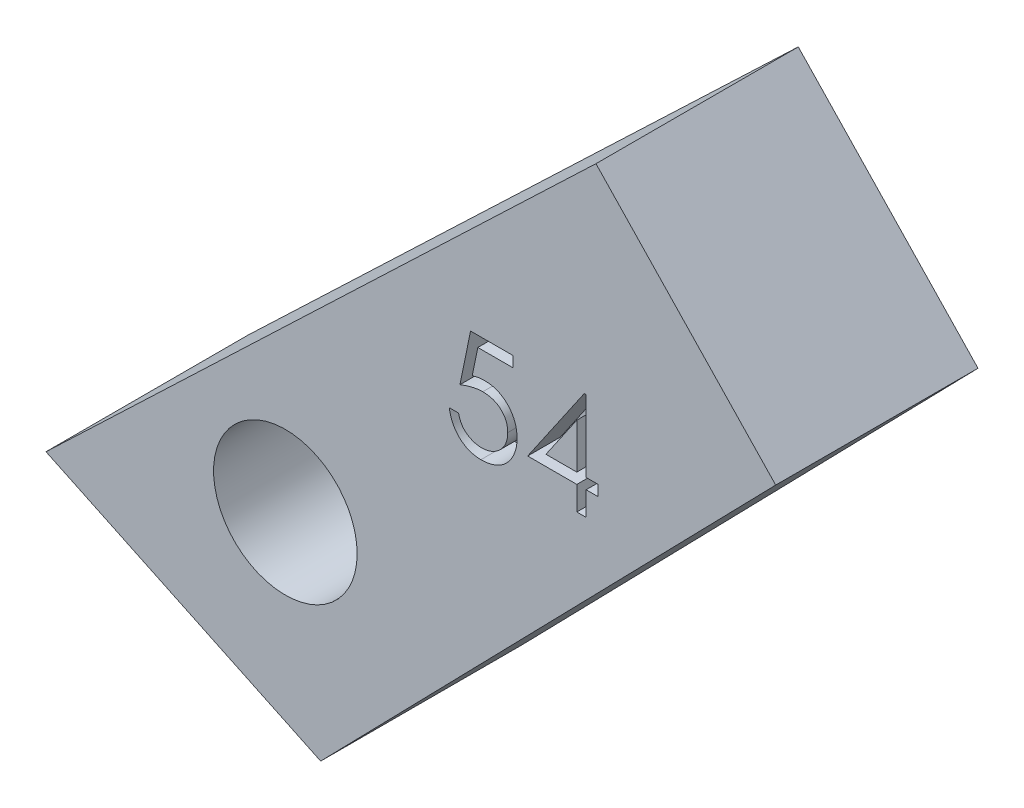
from build123d import *

# Parameters (mm, degrees)
SKETCH1_R           = 2.2
BOSS_EXTRUDE1_DEPTH = 6.2
CUT_EXTRUDE1_DEPTH  = 1


with BuildPart() as part:
    # Sketch1 → Boss-Extrude1 (new body)
    with BuildSketch(Plane(origin=(0, 0, 0), x_dir=(-1, 0, 0), z_dir=(0, 0, 1))):
        Polygon((-135.861235396, 102.40882942), (-149.806405315, 88.109421961), (-144.298520867, 82.333425686), (-134.435779681, 91.738355366), (-127.443880814, 98.405702296), align=None)
        with Locations((-134.779596853, 96.344682986)):
            Circle(SKETCH1_R, mode=Mode.SUBTRACT)
    extrude(amount=BOSS_EXTRUDE1_DEPTH)

    # Sketch2 → Cut-Extrude1 (cut)
    with BuildSketch(Plane.XY.offset(6.2)):
        with BuildLine():
            Line((141.757865871, -88.696242194), (141.757865871, -89.021883219))
            Line((141.757865871, -89.021883219), (140.677907938, -89.021883219))
            Line((140.677907938, -89.021883219), (140.506819196, -89.856974365))
            add(Edge.make_bspline(
                [(140.506819196, -89.856974365), (140.540434168, -89.847694047), (140.605557859, -89.829714899), (140.70167859, -89.809752521), (140.792930089, -89.797718869), (140.852144175, -89.796075751), (140.880797562, -89.795280655)],
                knots=[0, 0, 0, 0, 0.000104595, 0.000202637, 0.000294305, 0.000380252, 0.000380252, 0.000380252, 0.000380252], degree=3))
            add(Edge.make_bspline(
                [(140.880797562, -89.795280655), (140.916252097, -89.79604804), (140.985964572, -89.79755691), (141.087962759, -89.812045659), (141.185329027, -89.834851153), (141.277859748, -89.866710483), (141.365726105, -89.907450027), (141.448119678, -89.958340687), (141.526277214, -90.01778878), (141.598796567, -90.08613747), (141.664586475, -90.161359222), (141.722431337, -90.242238148), (141.771564544, -90.327988241), (141.811080372, -90.419428794), (141.842634732, -90.515548883), (141.863636899, -90.617359868), (141.877622056, -90.723902092), (141.879184507, -90.796749809), (141.879981255, -90.833897442)],
                knots=[0, 0, 0, 0, 0.000106308, 0.000209029, 0.000308378, 0.000405929, 0.000502102, 0.000598312, 0.00069588, 0.000796219, 0.000896736, 0.000995218, 0.001094066, 0.001192613, 0.001293582, 0.001396995, 0.001504047, 0.001615439, 0.001615439, 0.001615439, 0.001615439], degree=3))
            add(Edge.make_bspline(
                [(141.879981255, -90.833897442), (141.879377937, -90.859771171), (141.878179454, -90.911168967), (141.872084735, -90.987499777), (141.860350193, -91.062214633), (141.844595186, -91.135323445), (141.824145992, -91.206687805), (141.799390922, -91.276511976), (141.769095954, -91.34436137), (141.735866064, -91.410877978), (141.698449616, -91.474558052), (141.65692197, -91.534111061), (141.61304756, -91.590430374), (141.565838589, -91.642911975), (141.514856258, -91.691210998), (141.460718002, -91.735614082), (141.403855821, -91.776872146), (141.343389994, -91.813310437), (141.280667885, -91.846841119), (141.214783716, -91.874348899), (141.147237224, -91.898942021), (141.077056229, -91.91854495), (141.004399699, -91.933905196), (140.929147867, -91.944337883), (140.851695402, -91.951936509), (140.799194498, -91.952412175), (140.772674565, -91.95265245)],
                knots=[0, 0, 0, 0, 7.7636e-05, 0.000154223, 0.000229512, 0.000304362, 0.000378447, 0.000452077, 0.000526407, 0.000601214, 0.00067506, 0.000747747, 0.00081887, 0.000889121, 0.000959302, 0.001029336, 0.001099058, 0.00116985, 0.001240974, 0.00131221, 0.00138383, 0.001456517, 0.001530612, 0.001606437, 0.001684346, 0.001763871, 0.001763871, 0.001763871, 0.001763871], degree=3))
            add(Edge.make_bspline(
                [(140.772674565, -91.95265245), (140.741038701, -91.952025761), (140.678798876, -91.950792825), (140.587612361, -91.937894628), (140.499878398, -91.919421647), (140.416303235, -91.891630173), (140.336137874, -91.856807413), (140.260461551, -91.812796315), (140.187340597, -91.762922414), (140.119747535, -91.704066665), (140.057013061, -91.63973601), (140.000855014, -91.569924436), (139.950840983, -91.495784156), (139.907771884, -91.416955116), (139.871034394, -91.333644449), (139.842173654, -91.245540013), (139.818879718, -91.153102152), (139.809025044, -91.089462896), (139.804019717, -91.05713963)],
                knots=[0, 0, 0, 0, 9.4843e-05, 0.000186593, 0.000275792, 0.000363484, 0.000450342, 0.000537514, 0.000625728, 0.000715478, 0.000805885, 0.000894984, 0.00098389, 0.001073836, 0.001164117, 0.001256635, 0.001351658, 0.001449737, 0.001449737, 0.001449737, 0.001449737], degree=3))
            Line((139.804019717, -91.05713963), (140.088955614, -91.05713963))
            add(Edge.make_bspline(
                [(140.088955614, -91.05713963), (140.09596652, -91.08741684), (140.10944187, -91.14561132), (140.139019942, -91.227373322), (140.175183986, -91.300234332), (140.218186502, -91.365158169), (140.269485459, -91.421772045), (140.328022869, -91.472224665), (140.393652589, -91.517740675), (140.466580733, -91.5556799), (140.543518312, -91.588036555), (140.624042853, -91.609582735), (140.705961796, -91.624732831), (140.761368603, -91.626249357), (140.789211023, -91.627011425)],
                knots=[0, 0, 0, 0, 9.3172e-05, 0.000179081, 0.000260145, 0.000336703, 0.000411917, 0.000488562, 0.000568128, 0.000650923, 0.00073478, 0.000817953, 0.000900557, 0.000983994, 0.000983994, 0.000983994, 0.000983994], degree=3))
            add(Edge.make_bspline(
                [(140.789211023, -91.627011425), (140.816387612, -91.626266862), (140.869898538, -91.624800811), (140.948648867, -91.613516851), (141.024679117, -91.596138197), (141.097239077, -91.570130542), (141.167598473, -91.538521405), (141.233977536, -91.497958443), (141.298296575, -91.451276855), (141.358556382, -91.397794769), (141.413746454, -91.338857975), (141.462510935, -91.275832054), (141.503129992, -91.208597486), (141.53736022, -91.138318269), (141.563352855, -91.064224149), (141.581895745, -90.986662369), (141.592784234, -90.905441351), (141.59428209, -90.850042763), (141.595045358, -90.821813107)],
                knots=[0, 0, 0, 0, 8.15e-05, 0.000160473, 0.000238226, 0.000315066, 0.000391338, 0.000469218, 0.000547964, 0.000629516, 0.000710512, 0.000789892, 0.000868102, 0.000945761, 0.001024012, 0.00110315, 0.001184644, 0.001269321, 0.001269321, 0.001269321, 0.001269321], degree=3))
            add(Edge.make_bspline(
                [(141.595045358, -90.821813107), (141.594448023, -90.79634439), (141.593278825, -90.746492999), (141.583726093, -90.673559433), (141.567109983, -90.604550316), (141.544046892, -90.539132404), (141.514764767, -90.477243995), (141.478981326, -90.418821219), (141.43602503, -90.364634099), (141.386955959, -90.314657283), (141.333200451, -90.268533718), (141.273833627, -90.229214439), (141.210097836, -90.196136457), (141.142760985, -90.167590487), (141.070221399, -90.147088382), (140.993915596, -90.131696086), (140.913019583, -90.12279215), (140.857710459, -90.121556723), (140.829280134, -90.120921681)],
                knots=[0, 0, 0, 0, 7.6388e-05, 0.000149519, 0.000220172, 0.000288967, 0.000357247, 0.000425206, 0.000494043, 0.000564207, 0.000635056, 0.000706145, 0.000777268, 0.000850264, 0.000925136, 0.001002969, 0.001083601, 0.001168886, 0.001168886, 0.001168886, 0.001168886], degree=3))
            add(Edge.make_bspline(
                [(140.829280134, -90.120921681), (140.80467032, -90.12144836), (140.753857297, -90.122535819), (140.675913019, -90.130542712), (140.594005527, -90.143459787), (140.508448806, -90.161227311), (140.418985917, -90.184478359), (140.325805653, -90.212340799), (140.228712097, -90.245652898), (140.163291019, -90.270809978), (140.129660743, -90.283742194)],
                knots=[0, 0, 0, 0, 7.3822e-05, 0.000152423, 0.000234822, 0.000322511, 0.00041445, 0.000512043, 0.000614219, 0.000722306, 0.000722306, 0.000722306, 0.000722306], degree=3))
            Line((140.129660743, -90.283742194), (140.455301768, -88.696242194))
            Line((140.455301768, -88.696242194), (141.757865871, -88.696242194))
        make_face()
        Polygon((143.938770318, -88.614831937), (143.996647922, -88.614831937), (143.996647922, -90.81290886), (144.362994076, -90.81290886), (144.362994076, -91.138549886), (143.996647922, -91.138549886), (143.996647922, -91.871242194), (143.711712025, -91.871242194), (143.711712025, -91.138549886), (142.205622281, -91.138549886), align=None)
        Polygon((143.711712025, -90.81290886), (143.711712025, -89.434022643), (142.765317794, -90.81290886), align=None, mode=Mode.SUBTRACT)
    extrude(amount=-CUT_EXTRUDE1_DEPTH, mode=Mode.SUBTRACT)


solid = part.part
